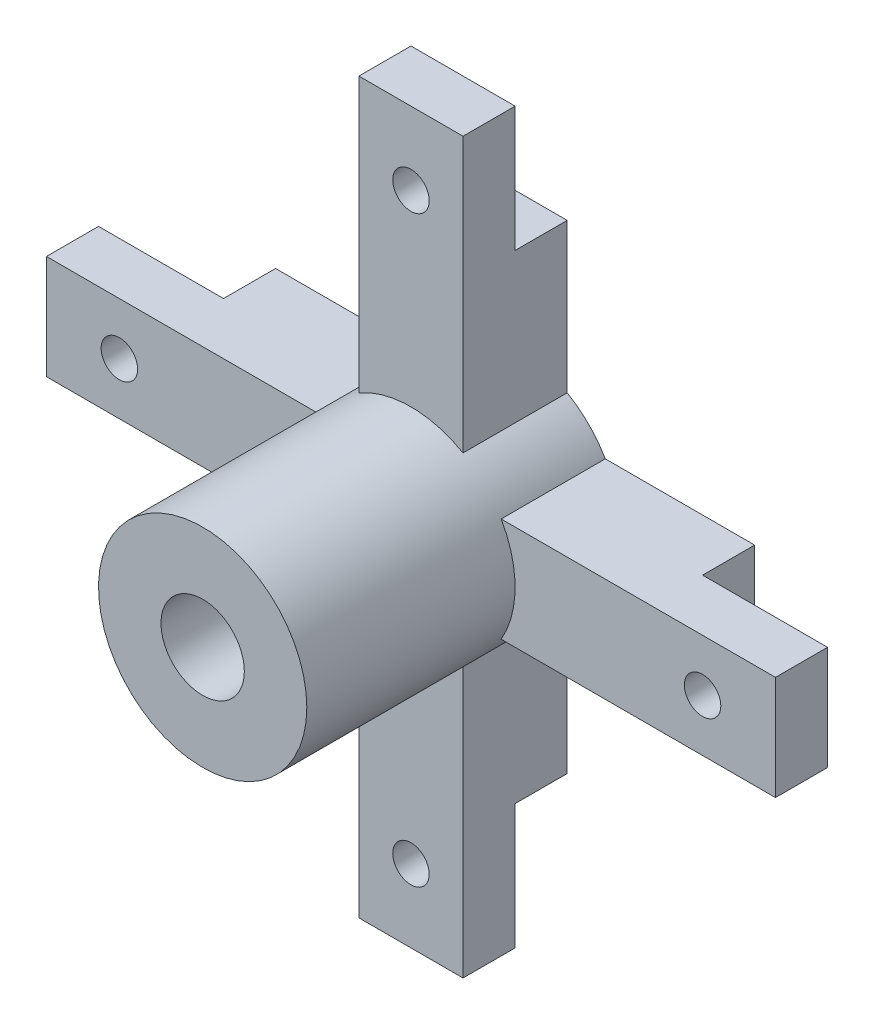
from build123d import *

# Parameters (mm, degrees)
SKETCH_1_R               = 10
SKETCH_1_R_2             = 4
EXTRUDE_1_DEPTH          = 30
SKETCH_2_W               = 10
SKETCH_2_H               = 31
EXTRUDE_2_DEPTH          = 10
SKETCH_3_W               = 10
SKETCH_3_H               = 12
CUT_EXTRUDE_1_DEPTH      = 5
HOLE_WIZARD_3_5_3_5_1_D  = 3.5
PATTERN_CIRCULAR_1_COUNT = 4


with BuildPart() as part:
    # Эскиз1 → Бобышка-Вытянуть1 (new body)
    with BuildSketch(Plane.XY):
        Circle(SKETCH_1_R)
        Circle(SKETCH_1_R_2, mode=Mode.SUBTRACT)
    extrude(amount=EXTRUDE_1_DEPTH)

    # Эскиз2 → Бобышка-Вытянуть2 (add)
    with BuildSketch(Plane(origin=(0, 0, 0), x_dir=(-1, 0, 0), z_dir=(0, 0, -1))):
        with Locations((0, 19.5)):
            Rectangle(SKETCH_2_W, SKETCH_2_H)
    extrude_2 = extrude(amount=-EXTRUDE_2_DEPTH)

    # Эскиз3 → Вырез-Вытянуть1 (cut)
    with BuildSketch(Plane(origin=(0, 0, 0), x_dir=(-1, 0, 0), z_dir=(0, 0, -1))):
        with Locations((0, 29)):
            Rectangle(SKETCH_3_W, SKETCH_3_H)
    cut_extrude_1 = extrude(amount=-CUT_EXTRUDE_1_DEPTH, mode=Mode.SUBTRACT)

    # Диаметр отверстия Ø3.5 (3.5)1 (through all)
    with Locations(Plane(origin=(0, 0, 5), x_dir=(-1, 0, 0), z_dir=(0, 0, -1))):
        with Locations((0, 28)):
            hole_wizard_3_5_3_5_1 = Hole(HOLE_WIZARD_3_5_3_5_1_D / 2)

    # Круговой массив1: Бобышка-Вытянуть2, Вырез-Вытянуть1, Диаметр отверстия Ø3.5 (3.5)1 ×4 about axis
    pattern_circular_1_axis = Axis((0, 0, 0), (0, 0, 1))
    for i in range(1, PATTERN_CIRCULAR_1_COUNT):
        add(extrude_2.rotate(pattern_circular_1_axis, i * 360 / PATTERN_CIRCULAR_1_COUNT))
        add(cut_extrude_1.rotate(pattern_circular_1_axis, i * 360 / PATTERN_CIRCULAR_1_COUNT), mode=Mode.SUBTRACT)
        add(hole_wizard_3_5_3_5_1.rotate(pattern_circular_1_axis, i * 360 / PATTERN_CIRCULAR_1_COUNT), mode=Mode.SUBTRACT)


solid = part.part
